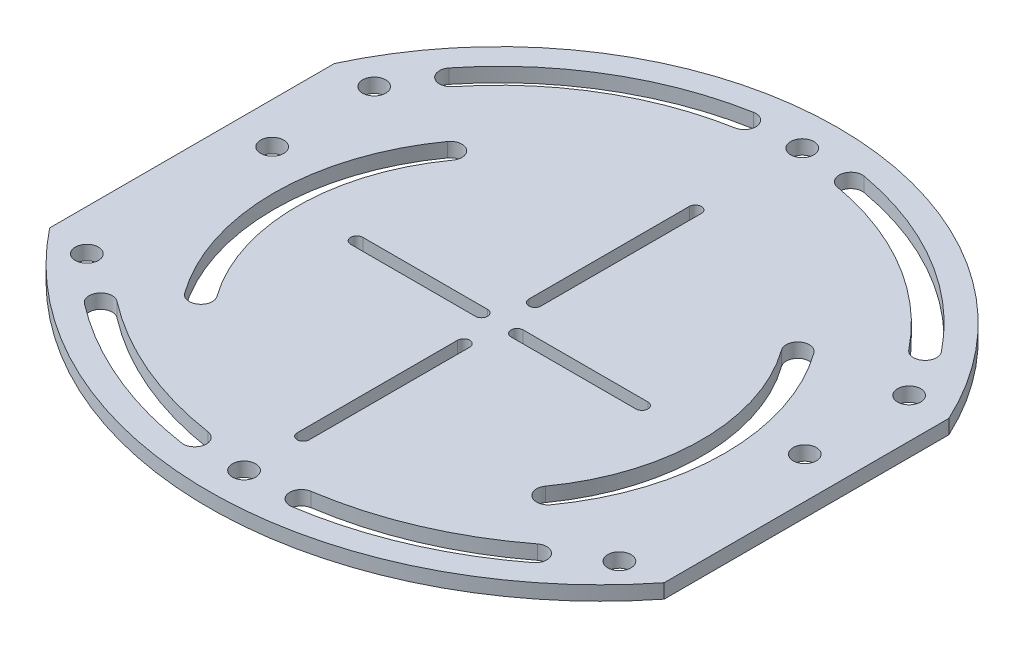
from build123d import *

# Parameters (mm, degrees)
BOSS_EXTRUDE1_DEPTH     = 2
SKETCH2_R               = 3.25
CUT_HOLES_DEPTH         = 3
CUT_HOLES_DEPTH_BACK    = 3
CUT_EXTRUDE1_DEPTH      = 3
CUT_EXTRUDE1_DEPTH_BACK = 3


with BuildPart() as part:
    # Sketch1 → Boss-Extrude1 (new body, symmetric)
    with BuildSketch(Plane(origin=(0, 0, 0), x_dir=(1, 0, 0), z_dir=(0, 1, 0))):
        with BuildLine():
            Line((86.2, 39.931942102), (86.2, -39.931942102))
            ThreePointArc((86.2, -39.931942102), (0, -81.597763245), (-86.2, -39.931942102))
            Line((-86.2, -39.931942102), (-86.2, 39.931942102))
            ThreePointArc((-86.2, 39.931942102), (0, 95), (86.2, 39.931942102))
        make_face()
    extrude(amount=BOSS_EXTRUDE1_DEPTH, both=True)

    # Sketch2 → Cut-Holes (cut, two sides)
    with BuildSketch(Plane(origin=(0, 0, 0), x_dir=(1, 0, 0), z_dir=(0, 1, 0))) as cut_holes_sk:
        with Locations((-74.7, 11)):
            Circle(SKETCH2_R)
        with Locations((-74.7, -41)):
            Circle(SKETCH2_R)
        with Locations((74.7, -41)):
            Circle(SKETCH2_R)
        with Locations((74.7, 11)):
            Circle(SKETCH2_R)
        with Locations((0, -71.597763245)):
            Circle(SKETCH2_R)
        with Locations((0, 85)):
            Circle(SKETCH2_R)
        with Locations((-75.036257902, 39.931942102)):
            Circle(SKETCH2_R)
        with Locations((75.036257902, 39.931942102)):
            Circle(SKETCH2_R)
        with BuildLine():
            ThreePointArc((14.471626034, -67.259325745), (11.744315506, -70.958890218), (15.443879979, -73.686200745))
            ThreePointArc((15.443879979, -73.686200745), (40.475581865, -66.58349782), (62.936747266, -53.448409812))
            ThreePointArc((62.936747266, -53.448409812), (63.532100029, -48.890937367), (58.974627584, -48.295584605))
            ThreePointArc((58.974627584, -48.295584605), (37.92748228, -60.603766345), (14.471626034, -67.259325745))
        make_face()
        with BuildLine():
            ThreePointArc((-62.936747266, -53.448409812), (-63.532100029, -48.890937367), (-58.974627584, -48.295584605))
            ThreePointArc((-58.974627584, -48.295584605), (-37.92748228, -60.603766345), (-14.471626034, -67.259325745))
            ThreePointArc((-14.471626034, -67.259325745), (-11.744315506, -70.958890218), (-15.443879979, -73.686200745))
            ThreePointArc((-15.443879979, -73.686200745), (-40.475581865, -66.58349782), (-62.936747266, -53.448409812))
        make_face()
        with BuildLine():
            ThreePointArc((-63.94162293, 50.936542452), (-68.508644796, 50.419520904), (-69.025666344, 54.98654277))
            ThreePointArc((-69.025666344, 54.98654277), (-45.1765399, 75.809911903), (-15.512787354, 86.875865052))
            ThreePointArc((-15.512787354, 86.875865052), (-11.742100438, 84.24776304), (-14.37020245, 80.477076125))
            ThreePointArc((-14.37020245, 80.477076125), (-41.849089369, 70.226179015), (-63.94162293, 50.936542452))
        make_face()
        with BuildLine():
            ThreePointArc((15.512787354, 86.875865052), (11.742100438, 84.24776304), (14.37020245, 80.477076125))
            ThreePointArc((14.37020245, 80.477076125), (41.849089369, 70.226179015), (63.94162293, 50.936542452))
            ThreePointArc((63.94162293, 50.936542452), (68.508644796, 50.419520904), (69.025666344, 54.98654277))
            ThreePointArc((69.025666344, 54.98654277), (45.1765399, 75.809911903), (15.512787354, 86.875865052))
        make_face()
    extrude(amount=CUT_HOLES_DEPTH, mode=Mode.SUBTRACT)
    extrude(cut_holes_sk.sketch, amount=-CUT_HOLES_DEPTH_BACK, mode=Mode.SUBTRACT)

    # Sketch3 → Cut-Extrude1 (cut, two sides)
    with BuildSketch(Plane(origin=(0, 0, 0), x_dir=(1, 0, 0), z_dir=(0, 1, 0))) as cut_extrude1_sk:
        with BuildLine():
            Line((5, 1.7), (40, 1.7))
            ThreePointArc((40, 1.7), (41.7, 0), (40, -1.7))
            Line((40, -1.7), (5, -1.7))
            ThreePointArc((5, -1.7), (3.3, 0), (5, 1.7))
        make_face()
        with BuildLine():
            Line((-5, -1.7), (-40, -1.7))
            ThreePointArc((-40, -1.7), (-41.7, 0), (-40, 1.7))
            Line((-40, 1.7), (-5, 1.7))
            ThreePointArc((-5, 1.7), (-3.3, 0), (-5, -1.7))
        make_face()
        with BuildLine():
            Line((-1.7, 55), (-1.7, 10))
            ThreePointArc((-1.7, 10), (0, 8.3), (1.7, 10))
            Line((1.7, 10), (1.7, 55))
            ThreePointArc((1.7, 55), (0, 56.7), (-1.7, 55))
        make_face()
        with BuildLine():
            Line((-1.7, -55), (-1.7, -10))
            ThreePointArc((-1.7, -10), (0, -8.3), (1.7, -10))
            Line((1.7, -10), (1.7, -55))
            ThreePointArc((1.7, -55), (0, -56.7), (-1.7, -55))
        make_face()
        with BuildLine():
            ThreePointArc((-46.094214922, 33.104166667), (-46.838138391, 37.639756802), (-51.373728526, 36.895833333))
            ThreePointArc((-51.373728526, 36.895833333), (-63.25, 0), (-51.373728526, -36.895833333))
            ThreePointArc((-51.373728526, -36.895833333), (-46.838138391, -37.639756802), (-46.094214922, -33.104166667))
            ThreePointArc((-46.094214922, -33.104166667), (-56.75, 0), (-46.094214922, 33.104166667))
        make_face()
        with BuildLine():
            ThreePointArc((51.373728526, -36.895833333), (46.838138391, -37.639756802), (46.094214922, -33.104166667))
            ThreePointArc((46.094214922, -33.104166667), (56.75, 0), (46.094214922, 33.104166667))
            ThreePointArc((46.094214922, 33.104166667), (46.838138391, 37.639756802), (51.373728526, 36.895833333))
            ThreePointArc((51.373728526, 36.895833333), (63.25, 0), (51.373728526, -36.895833333))
        make_face()
    extrude(amount=CUT_EXTRUDE1_DEPTH, mode=Mode.SUBTRACT)
    extrude(cut_extrude1_sk.sketch, amount=-CUT_EXTRUDE1_DEPTH_BACK, mode=Mode.SUBTRACT)


solid = part.part
